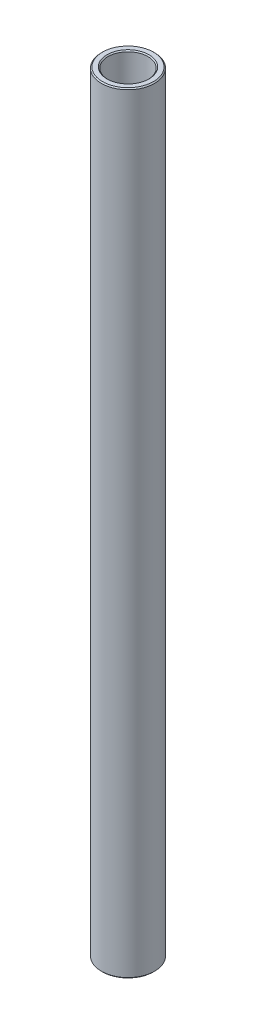
from build123d import *

# Parameters (mm, degrees)
SKETCH1_W     = 1.5875
SKETCH1_H     = 184.15
CHAMFER1_SIZE = 0.254


with BuildPart() as part:
    # Sketch1 → Revolve1 (revolve)
    with BuildSketch(Plane.XY):
        with Locations((5.55625, 0)):
            Rectangle(SKETCH1_W, SKETCH1_H)
    revolve(axis=Axis((0, 11.60859375, 0), (0, -1, 0)))

    # Chamfer1
    chamfer1_edges = [part.edges().sort_by_distance(p)[0] for p in [
        (-4.7625, -92.075, 0),
        (-6.35, -92.075, 0),
        (-6.35, 92.075, 0),
        (-4.7625, 92.075, 0),
    ]]
    chamfer(chamfer1_edges, length=CHAMFER1_SIZE)


solid = part.part
